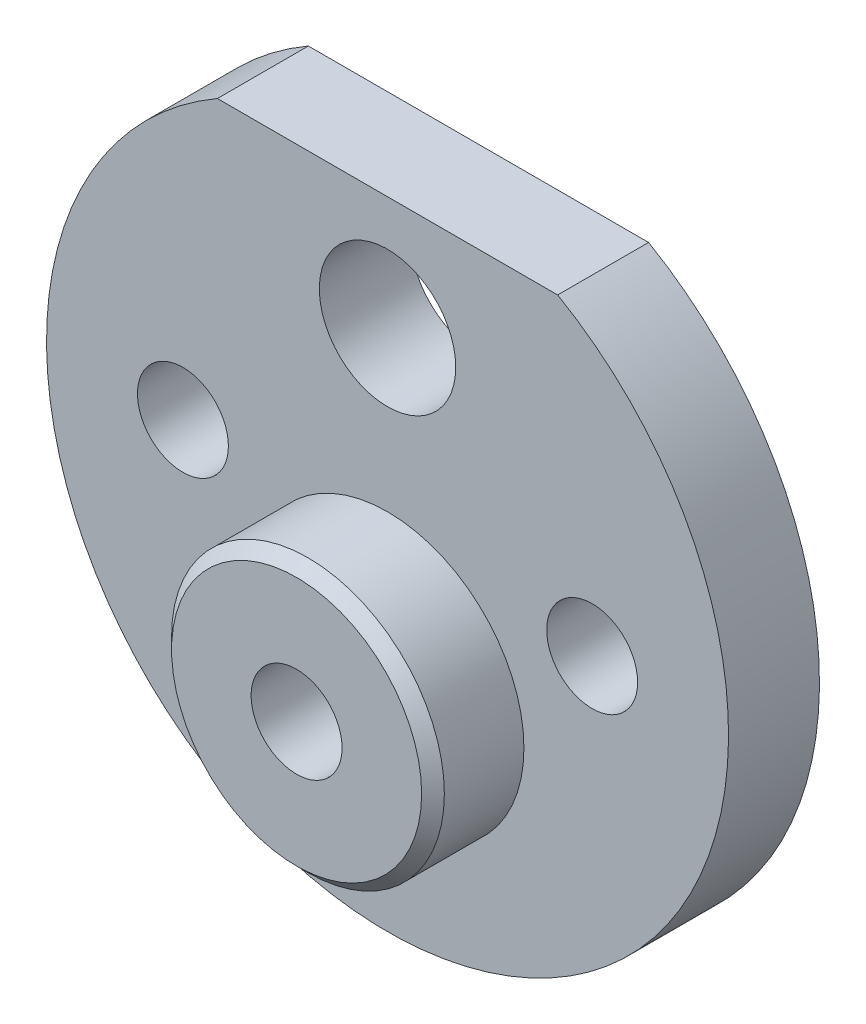
from build123d import *

# Parameters (mm, degrees)
SKETCH2_R           = 3
SKETCH2_R_2         = 2
BOSS_EXTRUDE1_DEPTH = 4
SKETCH3_R           = 6
BOSS_EXTRUDE2_DEPTH = 4
CHAMFER1_SIZE       = 0.5
SKETCH4_R           = 2
CUT_EXTRUDE1_DEPTH  = 9


with BuildPart() as part:
    # Sketch2 → Boss-Extrude1 (new body)
    with BuildSketch(Plane.XY):
        with BuildLine():
            Line((-7.483314774, 13), (7.483314774, 13))
            ThreePointArc((7.483314774, 13), (0, -15), (-7.483314774, 13))
        make_face()
        with Locations((0, 8)):
            Circle(SKETCH2_R, mode=Mode.SUBTRACT)
        with Locations((9, 0)):
            Circle(SKETCH2_R_2, mode=Mode.SUBTRACT)
        with Locations((-9, 0)):
            Circle(SKETCH2_R_2, mode=Mode.SUBTRACT)
    extrude(amount=BOSS_EXTRUDE1_DEPTH)

    # Sketch3 → Boss-Extrude2 (add)
    with BuildSketch(Plane.XY.offset(4)):
        with Locations((0, -5)):
            Circle(SKETCH3_R)
    extrude(amount=BOSS_EXTRUDE2_DEPTH)

    # Chamfer1
    chamfer1_edges = [part.edges().sort_by_distance(p)[0] for p in [
        (-6, -5, 8),
    ]]
    chamfer(chamfer1_edges, length=CHAMFER1_SIZE)

    # Sketch4 → Cut-Extrude1 (cut, through all)
    with BuildSketch(Plane.XY.offset(8)):
        with Locations((0, -5)):
            Circle(SKETCH4_R)
    extrude(amount=-CUT_EXTRUDE1_DEPTH, mode=Mode.SUBTRACT)


solid = part.part
